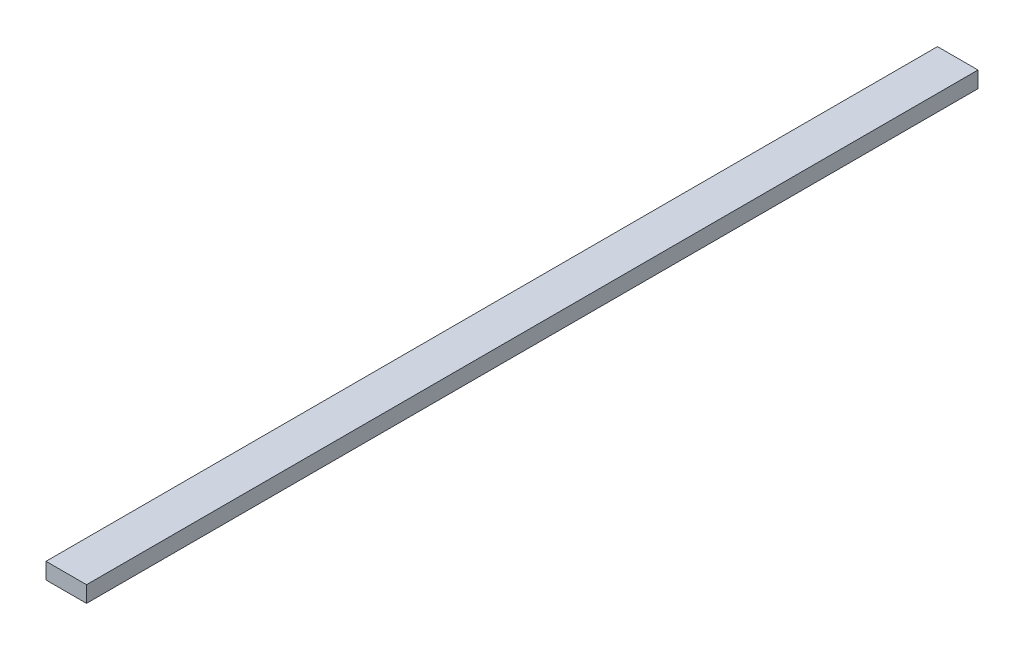
from build123d import *

# Parameters (mm, degrees)
SKETCH1_W           = 25
SKETCH1_H           = 550
BOSS_EXTRUDE1_DEPTH = 10


with BuildPart() as part:
    # Sketch1 → Boss-Extrude1 (new body)
    with BuildSketch(Plane(origin=(0, 0, 0), x_dir=(1, 0, 0), z_dir=(0, 1, 0))):
        with Locations((12.5, 275)):
            Rectangle(SKETCH1_W, SKETCH1_H)
    extrude(amount=BOSS_EXTRUDE1_DEPTH)


solid = part.part
